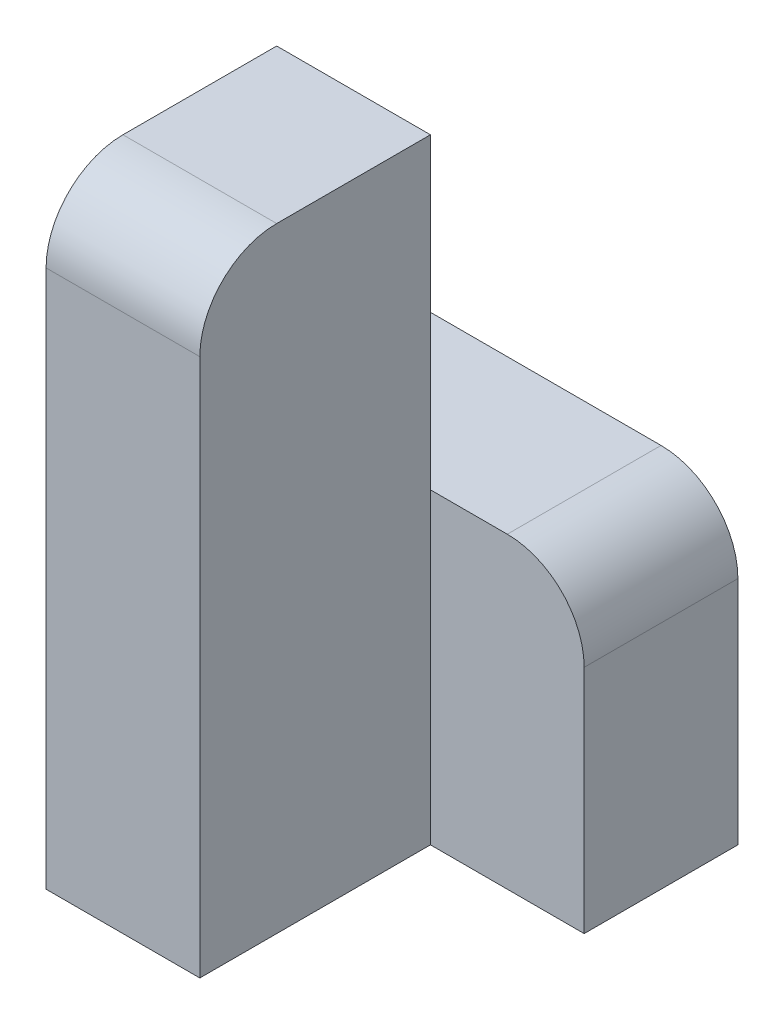
from build123d import *

# Parameters (mm, degrees)
SKETCH1_W           = 20
SKETCH1_H           = 80
BOSS_EXTRUDE1_DEPTH = 30
SKETCH2_W           = 40
SKETCH2_H           = 40
BOSS_EXTRUDE2_DEPTH = 20
FILLET1_R           = 10


with BuildPart() as part:
    # Sketch1 → Boss-Extrude1 (new body)
    with BuildSketch(Plane.XY):
        with Locations((-20, -40)):
            Rectangle(SKETCH1_W, SKETCH1_H)
    extrude(amount=BOSS_EXTRUDE1_DEPTH)

    # Sketch2 → Boss-Extrude2 (add)
    with BuildSketch(Plane.XY):
        with Locations((-10, -60)):
            Rectangle(SKETCH2_W, SKETCH2_H)
    extrude(amount=-BOSS_EXTRUDE2_DEPTH)

    # Fillet1
    fillet1_edges = [part.edges().sort_by_distance(p)[0] for p in [
        (10, -40, -10),
        (-20, 0, 30),
    ]]
    fillet(fillet1_edges, radius=FILLET1_R)


solid = part.part
